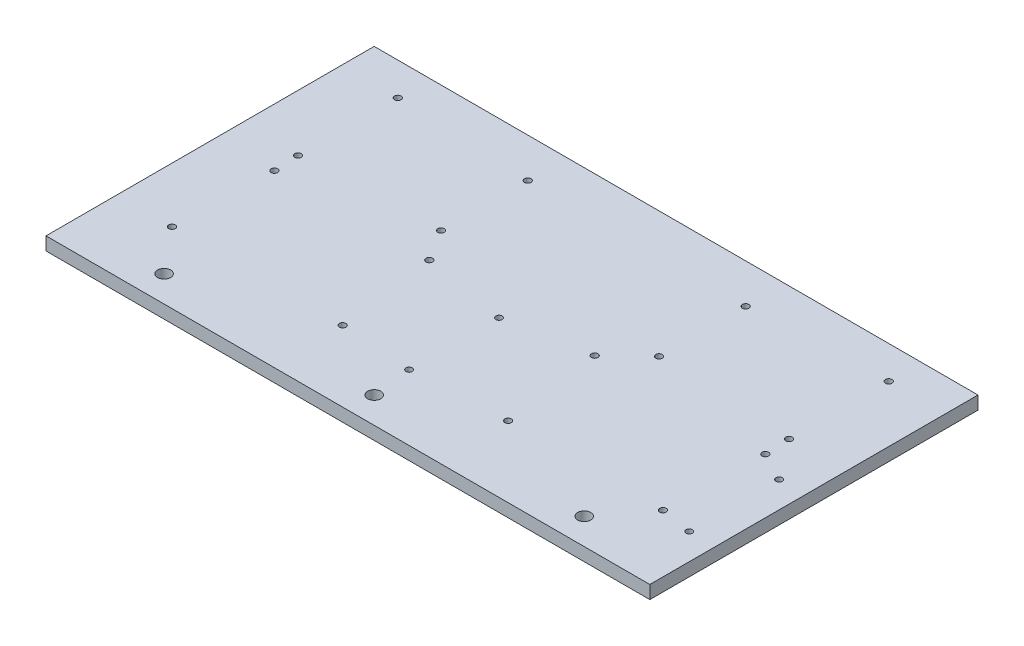
from build123d import *

# Parameters (mm, degrees)
SKETCH1_W           = 292.1
SKETCH1_H           = 158.75
BOSS_EXTRUDE1_DEPTH = 6.35
SKETCH2_R           = 3.175
CUT_EXTRUDE2_DEPTH  = 6.35
SKETCH4_R           = 1.5875
CUT_EXTRUDE3_DEPTH  = 7.35
SKETCH5_R           = 1.525
CUT_EXTRUDE4_DEPTH  = 7.35


with BuildPart() as part:
    # Sketch1 → Boss-Extrude1 (new body)
    with BuildSketch(Plane(origin=(0, 0, 0), x_dir=(1, 0, 0), z_dir=(0, 1, 0))):
        with Locations((146.05, 79.375)):
            Rectangle(SKETCH1_W, SKETCH1_H)
    extrude(amount=BOSS_EXTRUDE1_DEPTH)

    # Sketch2 → Cut-Extrude2 (cut)
    with BuildSketch(Plane(origin=(0, 6.35, 0), x_dir=(1, 0, 0), z_dir=(0, 1, 0))):
        with Locations((146.05, 12.7)):
            Circle(SKETCH2_R)
        with Locations((247.65, 12.7)):
            Circle(SKETCH2_R)
        with Locations((44.45, 12.7)):
            Circle(SKETCH2_R)
    extrude(amount=-CUT_EXTRUDE2_DEPTH, mode=Mode.SUBTRACT)

    # Sketch4 → Cut-Extrude3 (cut, through all)
    with BuildSketch(Plane(origin=(0, 6.35, 0), x_dir=(1, 0, 0), z_dir=(0, 1, 0))):
        with Locations((182.88, 82.55)):
            Circle(SKETCH4_R)
        with Locations((189.23, 34.29)):
            Circle(SKETCH4_R)
        with Locations((265.43, 82.55)):
            Circle(SKETCH4_R)
        with Locations((264.16, 34.29)):
            Circle(SKETCH4_R)
        with Locations((264.795, 142.875)):
            Circle(SKETCH4_R)
        with Locations((264.795, 94.615)):
            Circle(SKETCH4_R)
        with Locations((198.755, 97.79)):
            Circle(SKETCH4_R)
        with Locations((198.755, 139.7)):
            Circle(SKETCH4_R)
        with Locations((102.87, 82.55)):
            Circle(SKETCH4_R)
        with Locations((109.22, 34.29)):
            Circle(SKETCH4_R)
        with Locations((26.67, 34.29)):
            Circle(SKETCH4_R)
        with Locations((27.94, 82.55)):
            Circle(SKETCH4_R)
        with Locations((93.345, 139.7)):
            Circle(SKETCH4_R)
        with Locations((93.345, 97.79)):
            Circle(SKETCH4_R)
        with Locations((27.305, 142.875)):
            Circle(SKETCH4_R)
        with Locations((27.305, 94.615)):
            Circle(SKETCH4_R)
    extrude(amount=-CUT_EXTRUDE3_DEPTH, mode=Mode.SUBTRACT)

    # Sketch5 → Cut-Extrude4 (cut, through all)
    with BuildSketch(Plane(origin=(0, 6.35, 0), x_dir=(1, 0, 0), z_dir=(0, 1, 0))):
        with Locations((279.4, 31.75)):
            Circle(SKETCH5_R)
        with Locations((279.4, 75.25)):
            Circle(SKETCH5_R)
        with Locations((143.9, 75.25)):
            Circle(SKETCH5_R)
        with Locations((143.9, 31.75)):
            Circle(SKETCH5_R)
    extrude(amount=-CUT_EXTRUDE4_DEPTH, mode=Mode.SUBTRACT)


solid = part.part
